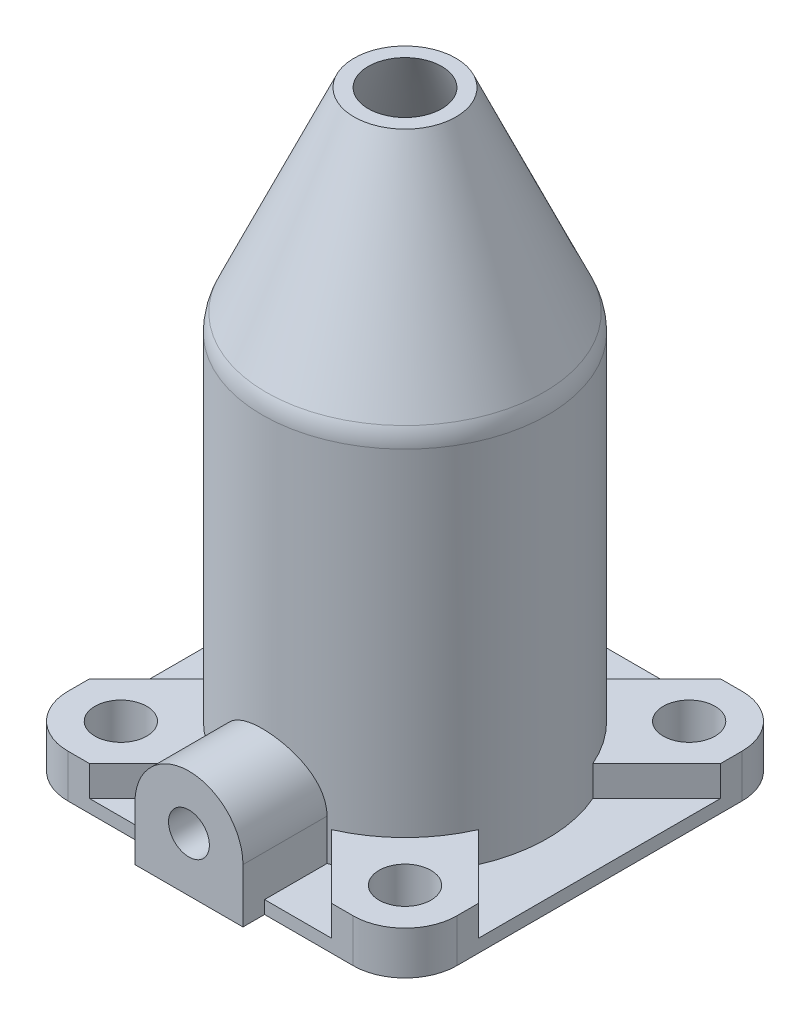
from build123d import *

# Parameters (mm, degrees)
BOSS_EXTRUDE1_DEPTH = 3
SKETCH2_R           = 30
CUT_EXTRUDE1_DEPTH  = 3
BOSS_EXTRUDE2_DEPTH = 7
SKETCH5_R           = 6
CUT_EXTRUDE2_DEPTH  = 10
CIRPATTERN1_COUNT   = 4
BOSS_EXTRUDE3_START = -14.459044
BOSS_EXTRUDE3_DEPTH = 19.459044
SKETCH8_R           = 4.725
CUT_EXTRUDE3_DEPTH  = 18
FILLET1_R           = 10


with BuildPart() as part:
    # Sketch1 → Boss-Extrude1 (new body)
    with BuildSketch(Plane(origin=(0, 0, 0), x_dir=(1, 0, 0), z_dir=(0, 1, 0))):
        with BuildLine():
            Line((-33, -45), (33, -45))
            ThreePointArc((33, -45), (41.485281374, -41.485281374), (45, -33))
            Line((45, -33), (45, 33))
            ThreePointArc((45, 33), (41.485281374, 41.485281374), (33, 45))
            Line((33, 45), (-33, 45))
            ThreePointArc((-33, 45), (-41.485281374, 41.485281374), (-45, 33))
            Line((-45, 33), (-45, -33))
            ThreePointArc((-45, -33), (-41.485281374, -41.485281374), (-33, -45))
        make_face()
    extrude(amount=BOSS_EXTRUDE1_DEPTH)

    # Sketch2 → Cut-Extrude1 (cut)
    with BuildSketch(Plane(origin=(0, 3, 0), x_dir=(1, 0, 0), z_dir=(0, 1, 0))):
        with Locations(Location((0, 0, 0), (0, 0, 270))):
            Circle(SKETCH2_R)
    extrude(amount=-CUT_EXTRUDE1_DEPTH, mode=Mode.SUBTRACT)

    # Sketch3 → Revolve1 (revolve)
    with BuildSketch(Plane.XY, mode=Mode.PRIVATE) as revolve1_sk:
        Polygon((30, 3), (30, 89.354466715), (8.5, 137), (11.79129626, 137), (33, 90), (33, 3), align=None)
    revolve(revolve1_sk.sketch.rotate(Axis((0, -84.852813742, 0), (0, 1, 0)), 90), axis=Axis((0, -84.852813742, 0), (0, 1, 0)))

    # Sketch4 → Boss-Extrude2 (add)
    with BuildSketch(Plane(origin=(0, 3, 0), x_dir=(1, 0, 0), z_dir=(0, 1, 0))):
        with BuildLine():
            Line((-13.251783745, -30.222346494), (-28.029437252, -45))
            Line((-28.029437252, -45), (-33, -45))
            ThreePointArc((-33, -45), (-41.485281374, -41.485281374), (-45, -33))
            Line((-45, -33), (-45, -28.029437252))
            Line((-45, -28.029437252), (-30.222346494, -13.251783745))
            ThreePointArc((-30.222346494, -13.251783745), (-23.334523779, -23.334523779), (-13.251783745, -30.222346494))
        make_face()
    boss_extrude2 = extrude(amount=BOSS_EXTRUDE2_DEPTH)

    # Sketch5 → Cut-Extrude2 (cut)
    with BuildSketch(Plane(origin=(0, 10, 0), x_dir=(1, 0, 0), z_dir=(0, 1, 0))):
        with Locations(Location((-32.880465325, -32.880465325, 0), (0, 0, 270))):
            Circle(SKETCH5_R)
    cut_extrude2 = extrude(amount=-CUT_EXTRUDE2_DEPTH, mode=Mode.SUBTRACT)

    # CirPattern1: Boss-Extrude2, Cut-Extrude2 ×4 about axis
    cirpattern1_axis = Axis((0, 0, 0), (0, 1, 0))
    add([boss_extrude2.rotate(cirpattern1_axis, i * 360 / CIRPATTERN1_COUNT) for i in range(1, CIRPATTERN1_COUNT)])
    add([cut_extrude2.rotate(cirpattern1_axis, i * 360 / CIRPATTERN1_COUNT) for i in range(1, CIRPATTERN1_COUNT)], mode=Mode.SUBTRACT)

    # Sketch6 → Boss-Extrude3 (add)
    with BuildSketch(Plane.XY.offset(45).offset(BOSS_EXTRUDE3_START)):
        with BuildLine():
            Line((-12.5, 12.5), (-12.5, 0))
            Line((-12.5, 0), (12.5, 0))
            Line((12.5, 0), (12.5, 12.5))
            ThreePointArc((12.5, 12.5), (0, 25), (-12.5, 12.5))
        make_face()
    extrude(amount=BOSS_EXTRUDE3_DEPTH)

    # Sketch8 → Cut-Extrude3 (cut)
    with BuildSketch(Plane.XY.offset(50)):
        with Locations((0, 12.5)):
            Circle(SKETCH8_R)
    extrude(amount=-CUT_EXTRUDE3_DEPTH, mode=Mode.SUBTRACT)

    # Fillet1
    fillet1_edges = [part.edges().sort_by_distance(p)[0] for p in [
        (0, 90, 33),
    ]]
    fillet(fillet1_edges, radius=FILLET1_R)


solid = part.part
